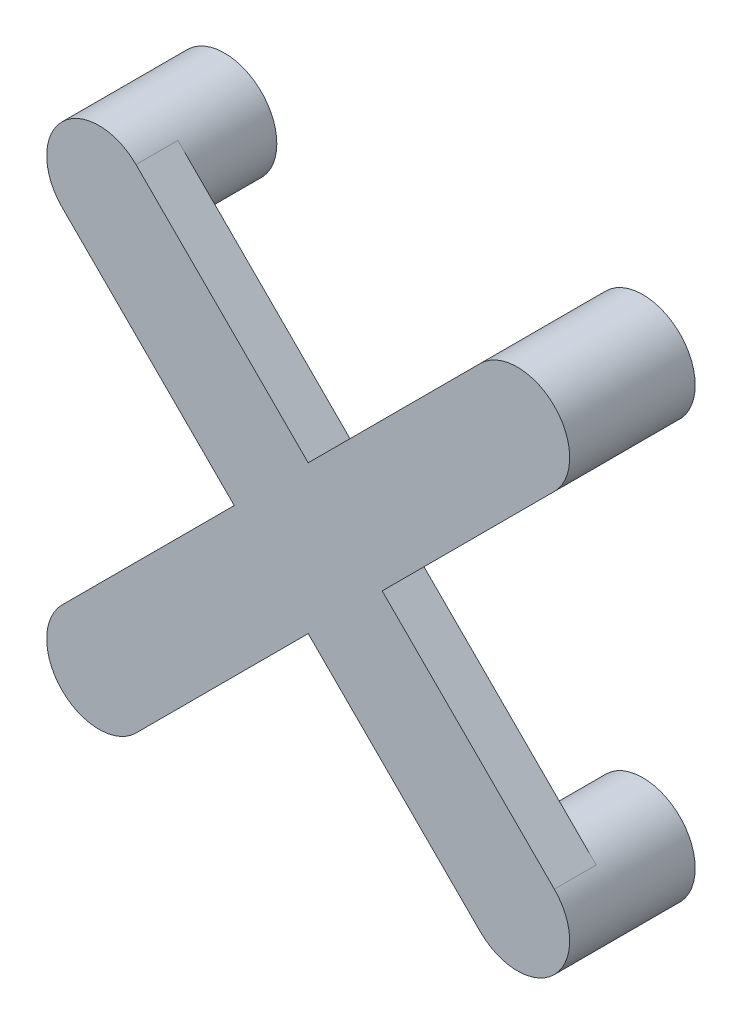
from build123d import *
from build123d.topology import SkipClean

# Parameters (mm, degrees)
ESQUISSE1_R          = 1.25
BOSS_EXTRU_1_DEPTH   = 2
BOSS_EXTRU_1_2_DEPTH = 2
BOSS_EXTRU_1_3_DEPTH = 2
BOSS_EXTRU_1_4_DEPTH = 2
BOSS_EXTRU_2_DEPTH   = 1


with BuildPart() as part:
    # Esquisse1 → Boss.-Extru.1 (new body)
    with BuildSketch(Plane.XY):
        with Locations((-5, 5)):
            Circle(ESQUISSE1_R)
    extrude(amount=BOSS_EXTRU_1_DEPTH)



with BuildPart() as body_2:
    # Esquisse1 → Boss.-Extru.1 2 (new body)
    with BuildSketch(Plane.XY):
        with Locations((5, 5)):
            Circle(ESQUISSE1_R)
    extrude(amount=BOSS_EXTRU_1_2_DEPTH)


with BuildPart() as body_3:
    # Esquisse1 → Boss.-Extru.1 3 (new body)
    with BuildSketch(Plane.XY):
        with Locations((5, -5)):
            Circle(ESQUISSE1_R)
    extrude(amount=BOSS_EXTRU_1_3_DEPTH)


with BuildPart() as body_4:
    # Esquisse1 → Boss.-Extru.1 4 (new body)
    with BuildSketch(Plane.XY):
        with Locations((-5, -5)):
            Circle(ESQUISSE1_R)
    extrude(amount=BOSS_EXTRU_1_4_DEPTH)


with BuildPart() as part_1:
    with SkipClean():  # keep this step's faces unmerged: merging them makes the solid invalid here
        add(part.part)

        add(body_2.part)  # Boss.-Extru.2 merges body 2

        add(body_3.part)  # Boss.-Extru.2 merges body 3

        add(body_4.part)  # Boss.-Extru.2 merges body 4
        # Esquisse2 → Boss.-Extru.2 (add)
        with BuildSketch(Plane.XY.offset(2)):
            with BuildLine():
                Line((-5.883883476, -4.116116524), (-1.767766953, 0))
                Line((-1.767766953, 0), (-5.883883476, 4.116116524))
                ThreePointArc((-5.883883476, 4.116116524), (-5.883883476, 5.883883476), (-4.116116524, 5.883883476))
                Line((-4.116116524, 5.883883476), (0, 1.767766953))
                Line((0, 1.767766953), (4.116116524, 5.883883476))
                ThreePointArc((4.116116524, 5.883883476), (5.883883476, 5.883883476), (5.883883476, 4.116116524))
                Line((5.883883476, 4.116116524), (1.767766953, 0))
                Line((1.767766953, 0), (5.883883476, -4.116116524))
                ThreePointArc((5.883883476, -4.116116524), (5.883883476, -5.883883476), (4.116116524, -5.883883476))
                Line((4.116116524, -5.883883476), (0, -1.767766953))
                Line((0, -1.767766953), (-4.116116524, -5.883883476))
                ThreePointArc((-4.116116524, -5.883883476), (-5.883883476, -5.883883476), (-5.883883476, -4.116116524))
            make_face()
        extrude(amount=BOSS_EXTRU_2_DEPTH)


solid = part_1.part
